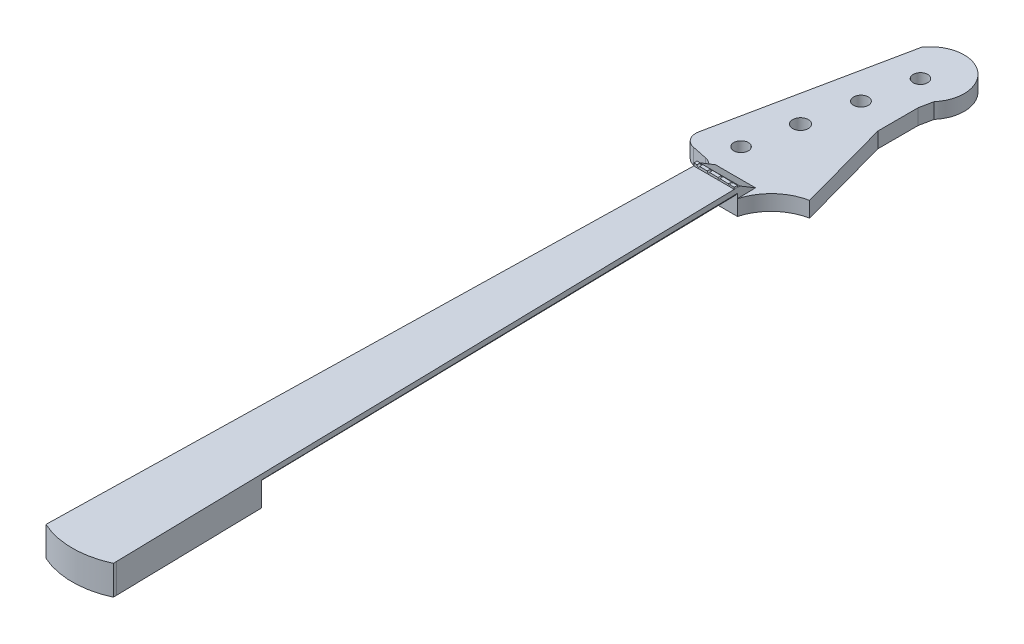
from build123d import *

# Parameters (mm, degrees)
SKETCH1_W           = 38.1
SKETCH1_H           = 4.826
SKETCH2_W           = 63.5
SKETCH2_H           = 4.826
BOSS_EXTRUDE1_DEPTH = 22.86
BOSS_EXTRUDE2_REACH = 601.968
SKETCH7_R           = 6.86435
SKETCH7_R_2         = 7.398290426
SKETCH7_R_3         = 6.940009574
BOSS_EXTRUDE3_DEPTH = 14.5542
BOSS_EXTRUDE4_REACH = 615.571
SKETCH9_R           = 2.06375
CUT_EXTRUDE1_DEPTH  = 10.16
BOSS_EXTRUDE5_DEPTH = 3.048


with BuildPart() as part:
    # Sketch1 → Loft1 section 0
    with BuildSketch(Plane.XY):
        with Locations((0, -2.413)):
            Rectangle(SKETCH1_W, SKETCH1_H)
    # Sketch2 → Loft1 section 1
    with BuildSketch(Plane.XY.offset(598.4875)):
        with Locations((0, -2.413)):
            Rectangle(SKETCH2_W, SKETCH2_H)
    loft()

    # Sketch5 → Boss-Extrude1 (add)
    with BuildSketch(Plane.XZ.offset(4.826)):
        Polygon((28.785543767, 458.7875), (31.75, 598.4875), (-31.75, 598.4875), (-28.785543767, 458.7875), align=None)
    extrude(amount=BOSS_EXTRUDE1_DEPTH)

    # Sketch4 for Loft2 → Loft2 section 0
    with BuildSketch(Plane.XY.offset(458.7875)):
        with BuildLine():
            Line((-28.785543767, -4.826), (28.785543767, -4.826))
            # circular arc as an exact rational Bezier (weights 1, cos(half-angle), 1)
            Bezier((28.785543767, -4.826), (0, -41.073048554), (-28.785543767, -4.826), weights=[1, 0.62189702, 1])
        make_face()
    # Sketch3 for Loft2 → Loft2 section 1
    with BuildSketch(Plane(origin=(0, 0, 0), x_dir=(-1, 0, 0), z_dir=(0, 0, -1))):
        with BuildLine():
            Line((19.05, -4.826), (-19.05, -4.826))
            Bezier((-19.05, -4.826), (0, -34.080271737), (19.05, -4.826), weights=[1, 0.545687389, 1])
        make_face()
    loft()

    # Boss-Extrude2: up to this face of the body (flat: up to its plane)
    boss_extrude2_end = Plane(part.part.faces().sort_by_distance((0, -27.686, 529.777696624))[0])
    # Sketch6 → Boss-Extrude2 (add, up to the picked face)
    with BuildSketch(Plane(origin=(0, 0, 0), x_dir=(1, 0, 0), z_dir=(0, 1, 0)), mode=Mode.PRIVATE) as boss_extrude2_sk1:
        with BuildLine():
            Line((-31.75, -598.4875), (-31.75, -601.5355))
            ThreePointArc((-31.75, -601.5355), (0, -608.5205), (31.75, -601.5355))
            Line((31.75, -601.5355), (31.75, -598.4875))
            Line((31.75, -598.4875), (-31.75, -598.4875))
        make_face()
    boss_extrude2_tool1 = split(extrude(boss_extrude2_sk1.sketch, amount=-BOSS_EXTRUDE2_REACH, mode=Mode.PRIVATE), bisect_by=boss_extrude2_end, keep=Keep.BOTH, mode=Mode.PRIVATE)
    add(boss_extrude2_tool1.solids().sort_by(Axis((0, 0, 602.638041), (0, -1, 0)))[0])

    # Sketch7 → Boss-Extrude3 (add)
    with BuildSketch(Plane(origin=(0, -23.749, 0), x_dir=(1, 0, 0), z_dir=(0, 1, 0))):
        with BuildLine():
            Line((-53.796563594, 36.394925453), (-17.858265722, 210.524988182))
            ThreePointArc((-17.858265722, 210.524988182), (27.686421042, 217.987818984), (32.564596867, 172.094292899))
            Line((32.564596867, 172.094292899), (29.99757559, 159.656431275))
            Line((29.99757559, 159.656431275), (29.99757559, 121.556431275))
            Line((29.99757559, 121.556431275), (54.47665, 32.656431275))
            ThreePointArc((54.47665, 32.656431275), (32.112450528, 21.373620039), (19.05, 0))
            Line((19.05, 0), (-19.05, 0))
            Line((-19.05, 0), (-19.05, 5.909460242))
            ThreePointArc((-19.05, 5.909460242), (-21.903905083, 13.930957291), (-29.182978723, 18.347321866))
            Line((-29.182978723, 18.347321866), (-43.925723247, 21.390042553))
            ThreePointArc((-43.925723247, 21.390042553), (-51.96875642, 26.848166031), (-53.796563594, 36.394925453))
        make_face()
        with Locations(Location((-21.72335, 44.196, 0), (0, 0, 180))):
            Circle(SKETCH7_R, mode=Mode.SUBTRACT)
        with Locations(Location((-12.122690426, 90.713602472, 0), (0, 0, 180))):
            Circle(SKETCH7_R_2, mode=Mode.SUBTRACT)
        with Locations(Location((-2.368009574, 137.977476641, 0), (0, 0, 180))):
            Circle(SKETCH7_R_3, mode=Mode.SUBTRACT)
        with Locations(Location((7.23265, 184.495079113, 0), (0, 0, 180))):
            Circle(SKETCH7_R, mode=Mode.SUBTRACT)
    extrude(amount=BOSS_EXTRUDE3_DEPTH)

    # Boss-Extrude4: up to this plane
    boss_extrude4_end = Plane(origin=(19.041425738, 0, -0.404062085), z_dir=(-0.999774928431425, 0, 0.021215383096688065))
    # Sketch8 → Boss-Extrude4 (add, up to the surface)
    with BuildSketch(Plane.ZY.offset(19.05), mode=Mode.PRIVATE) as boss_extrude4_sk1:
        Polygon((0, 0), (-2.286, 0), (-17.399, -9.1948), (0, -9.1948), align=None)
    boss_extrude4_tool1 = split(extrude(boss_extrude4_sk1.sketch, amount=-BOSS_EXTRUDE4_REACH, mode=Mode.PRIVATE), bisect_by=boss_extrude4_end, keep=Keep.BOTH, mode=Mode.PRIVATE)
    add(boss_extrude4_tool1.solids().sort_by_distance((-19.05, -5.773939, -5.888157))[0])

    # Sketch9 → Cut-Extrude1 (cut)
    with BuildSketch(Plane.XZ.offset(27.686)):
        with Locations((-18.459938241, 572.290233936)):
            Circle(SKETCH9_R)
        with Locations((18.968052603, 572.290233936)):
            Circle(SKETCH9_R)
        with Locations((19.026588432, 521.172733936)):
            Circle(SKETCH9_R)
        with Locations((-18.137388298, 521.172733936)):
            Circle(SKETCH9_R)
    extrude(amount=-CUT_EXTRUDE1_DEPTH, mode=Mode.SUBTRACT)

    # Sketch10 → Boss-Extrude5 (add)
    with BuildSketch(Plane.XY):
        with BuildLine():
            Line((-19.05, 0), (19.001490716, 0))
            Line((19.001490716, 0), (19.001490716, 1.6637))
            Line((19.001490716, 1.6637), (14.9098, 1.75792886))
            ThreePointArc((14.9098, 1.75792886), (14.286161326, 1.162367534), (13.6906, 1.786006208))
            Line((13.6906, 1.786006208), (5.505740514, 1.974497966))
            ThreePointArc((5.505740514, 1.974497966), (4.635244864, 1.143193615), (3.803940514, 2.013689264))
            Line((3.803940514, 2.013689264), (-4.283815101, 2.199944786))
            ThreePointArc((-4.283815101, 2.199944786), (-5.342420922, 1.188999326), (-6.353366381, 2.247605147))
            Line((-6.353366381, 2.247605147), (-13.5382, 2.413066988))
            ThreePointArc((-13.5382, 2.413066988), (-14.837447238, 1.172314226), (-16.0782, 2.471561463))
            Line((-16.0782, 2.471561463), (-19.05, 2.54))
            Line((-19.05, 2.54), (-19.05, 0))
        make_face()
    extrude(amount=BOSS_EXTRUDE5_DEPTH)


solid = part.part
